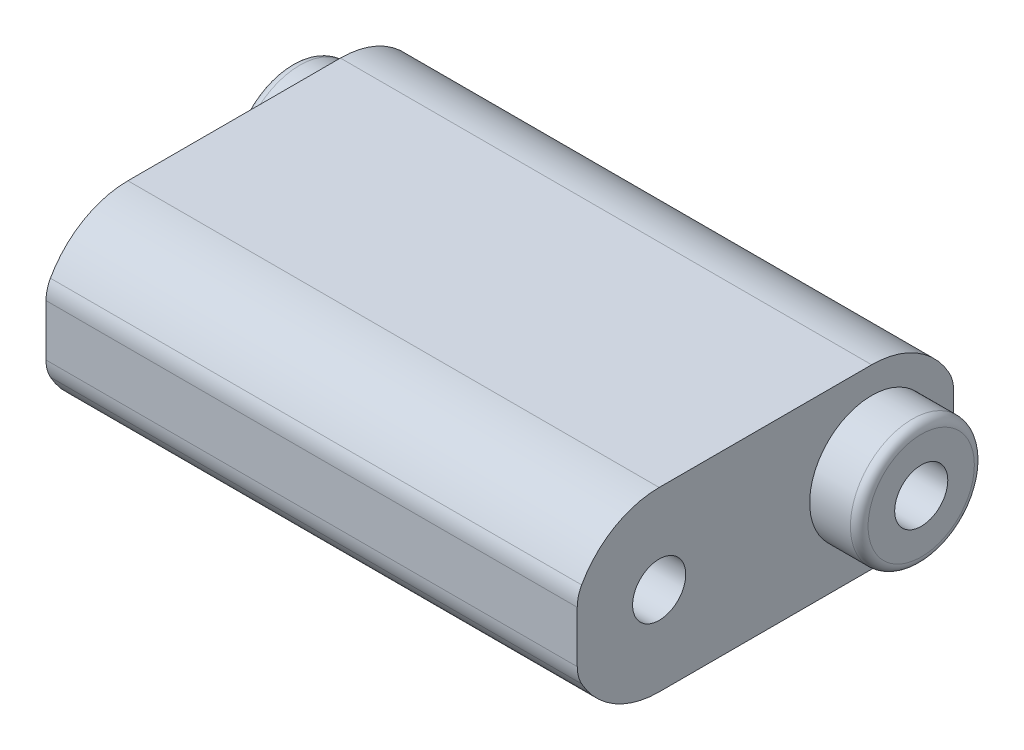
from build123d import *

# Parameters (mm, degrees)
SKETCH_2_W          = 120
SKETCH_2_H          = 100
EXTRUDE_1_DEPTH     = 300
SKETCH_3_R          = 15
CUT_EXTRUDE_1_DEPTH = 300
SKETCH_4_R          = 35
SKETCH_4_R_2        = 15
EXTRUDE_2_DEPTH     = 28
SKETCH_6_R          = 35
SKETCH_6_R_2        = 15
EXTRUDE_3_DEPTH     = 28
FILLET_2_R          = 5
FILLET_3_R          = 20


with BuildPart() as part:
    # 草图2 → 凸台-拉伸1 (new body)
    with BuildSketch(Plane(origin=(0, 0, 0), x_dir=(0, 0, -1), z_dir=(1, 0, 0))):
        with BuildLine():
            Line((106.249324319, 19), (106.249324319, -19))
            ThreePointArc((106.249324319, -19), (10, 0), (106.249324319, 19))
        make_face()
        Rectangle(SKETCH_2_W, SKETCH_2_H)
        with BuildLine():
            Line((-106.249324319, 19), (-106.249324319, -19))
            ThreePointArc((-106.249324319, -19), (-10, 0), (-106.249324319, 19))
        make_face()
    extrude(amount=EXTRUDE_1_DEPTH)

    # 草图3 → 切除-拉伸1 (cut)
    with BuildSketch(Plane.ZY):
        with Locations((60, 0)):
            Circle(SKETCH_3_R)
        with Locations((-60, 0)):
            Circle(SKETCH_3_R)
    extrude(amount=-CUT_EXTRUDE_1_DEPTH, mode=Mode.SUBTRACT)

    # 草图4 → 凸台-拉伸2 (add)
    with BuildSketch(Plane.ZY):
        with Locations((-60, 0)):
            Circle(SKETCH_4_R)
        with Locations((-60, 0)):
            Circle(SKETCH_4_R_2, mode=Mode.SUBTRACT)
    extrude(amount=EXTRUDE_2_DEPTH)

    # 草图6 → 凸台-拉伸3 (add)
    with BuildSketch(Plane(origin=(300, 0, 0), x_dir=(0, 0, -1), z_dir=(1, 0, 0))):
        with Locations((60, 0)):
            Circle(SKETCH_6_R)
        with Locations((60, 0)):
            Circle(SKETCH_6_R_2, mode=Mode.SUBTRACT)
    extrude(amount=EXTRUDE_3_DEPTH)

    # 圆角2
    fillet_2_edges = [part.edges().sort_by_distance(p)[0] for p in [
        (-28, 0, -95),
        (328, 0, -25),
    ]]
    fillet(fillet_2_edges, radius=FILLET_2_R)

    # 圆角3
    fillet_3_edges = [part.edges().sort_by_distance(p)[0] for p in [
        (150, -19, 106.249324319),
        (150, 19, 106.249324319),
        (150, 19, -106.249324319),
        (150, -19, -106.249324319),
    ]]
    fillet(fillet_3_edges, radius=FILLET_3_R)


solid = part.part
